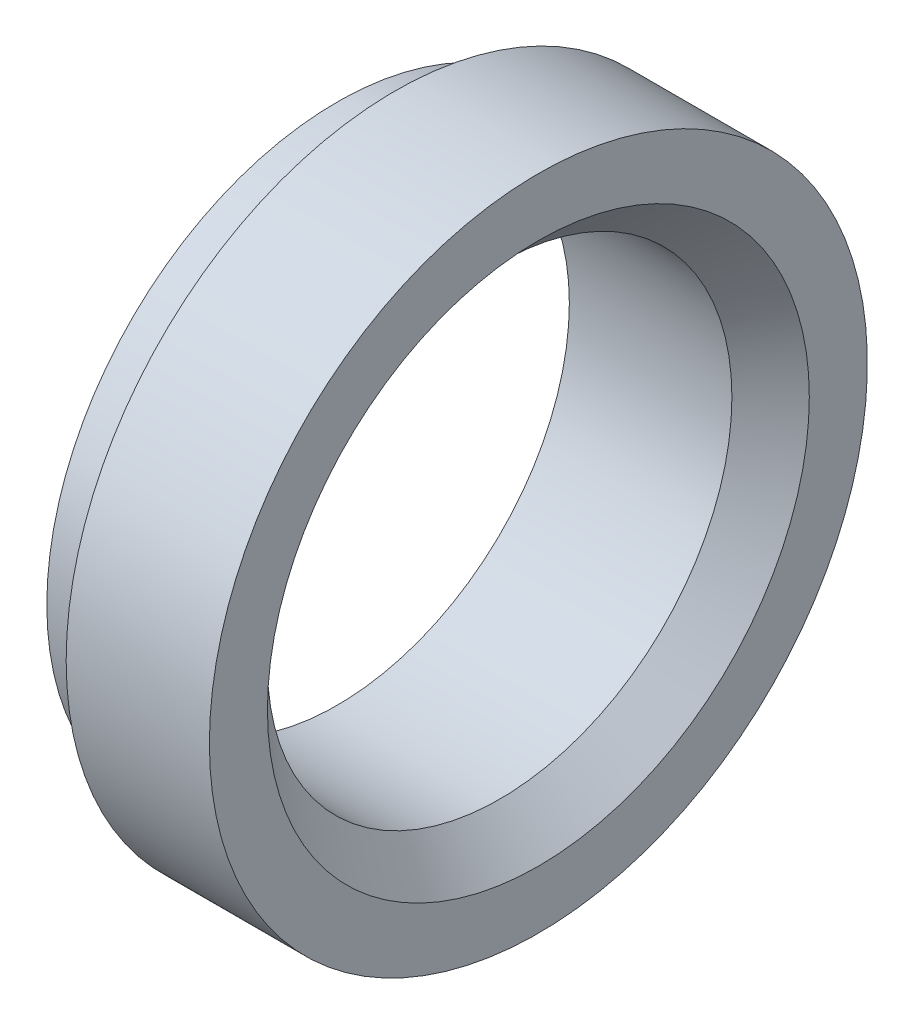
from build123d import *


with BuildPart() as part:
    # Sketch1 → Revolve4 (revolve)
    with BuildSketch(Plane.XY):
        Polygon((0, 6), (0, 7.5), (1.5, 7.5), (1.5, 8.5), (5.2, 8.5), (5.2, 7), (4.2, 6), align=None)
    revolve(axis=Axis((0, 0, 0), (1, 0, 0)))


solid = part.part
